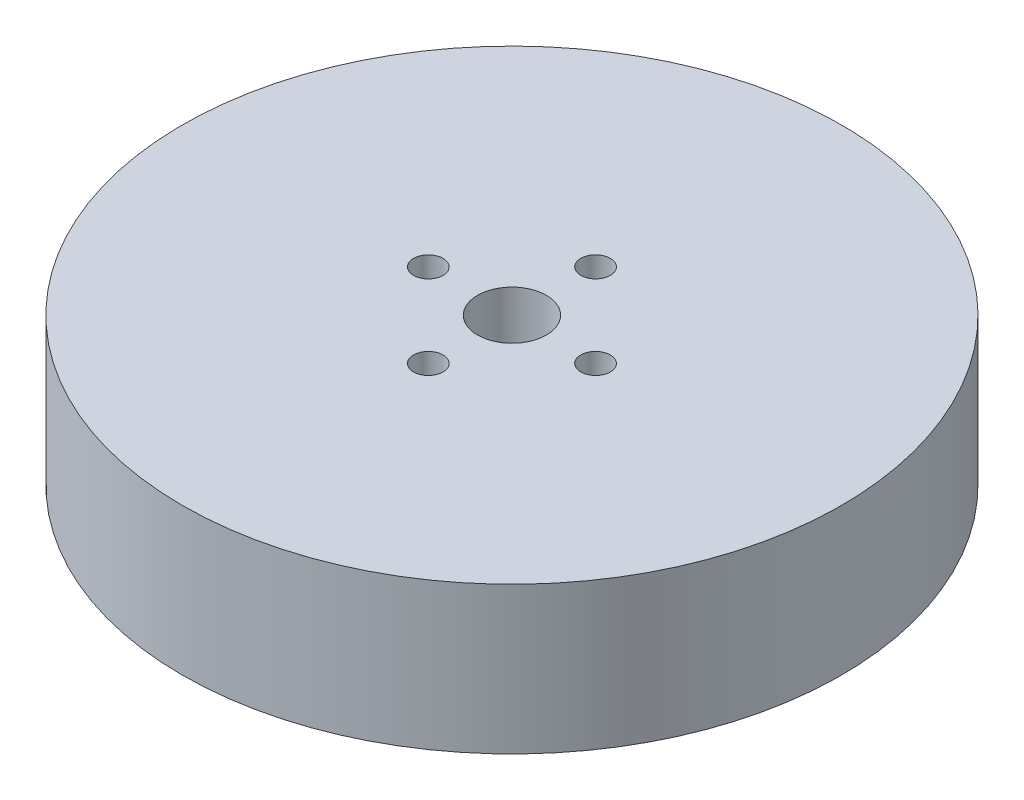
from build123d import *

# Parameters (mm, degrees)
SKETCH1_R               = 33.5
BOSS_EXTRUDE1_DEPTH     = 17
SKETCH2_R               = 3.5
CUT_EXTRUDE1_DEPTH      = 100
CUT_EXTRUDE1_DEPTH_BACK = 100
SKETCH3_R               = 1.5
CUT_EXTRUDE2_DEPTH      = 100
CUT_EXTRUDE2_DEPTH_BACK = 100
CHAMFER1_SIZE           = 13
CHAMFER1_SIZE2          = 2.058997724


with BuildPart() as part:
    # Sketch1 → Boss-Extrude1 (new body)
    with BuildSketch(Plane(origin=(0, 0, 0), x_dir=(1, 0, 0), z_dir=(0, 1, 0))):
        Circle(SKETCH1_R)
    extrude(amount=BOSS_EXTRUDE1_DEPTH)

    # Sketch2 → Cut-Extrude1 (cut, two sides)
    with BuildSketch(Plane(origin=(0, 0, 0), x_dir=(1, 0, 0), z_dir=(0, 1, 0))) as cut_extrude1_sk:
        Circle(SKETCH2_R)
    extrude(amount=CUT_EXTRUDE1_DEPTH, mode=Mode.SUBTRACT)
    extrude(cut_extrude1_sk.sketch, amount=-CUT_EXTRUDE1_DEPTH_BACK, mode=Mode.SUBTRACT)

    # Sketch3 → Cut-Extrude2 (cut, two sides)
    with BuildSketch(Plane(origin=(0, 0, 0), x_dir=(1, 0, 0), z_dir=(0, 1, 0))) as cut_extrude2_sk:
        with Locations((8.5, 0)):
            Circle(SKETCH3_R)
        with Locations((-8.5, 0)):
            Circle(SKETCH3_R)
        with Locations((0, -8.5)):
            Circle(SKETCH3_R)
        with Locations((0, 8.5)):
            Circle(SKETCH3_R)
    extrude(amount=CUT_EXTRUDE2_DEPTH, mode=Mode.SUBTRACT)
    extrude(cut_extrude2_sk.sketch, amount=-CUT_EXTRUDE2_DEPTH_BACK, mode=Mode.SUBTRACT)

    # Chamfer1
    chamfer1_edges = [part.edges().sort_by_distance(p)[0] for p in [
        (-33.5, 0, 0),
    ]]
    chamfer1_side = [part.faces().sort_by_distance(p)[0] for p in [
        (-32.552476913, 0, 0),
    ]]
    chamfer(chamfer1_edges, length=CHAMFER1_SIZE, length2=CHAMFER1_SIZE2, reference=chamfer1_side[0])


solid = part.part
